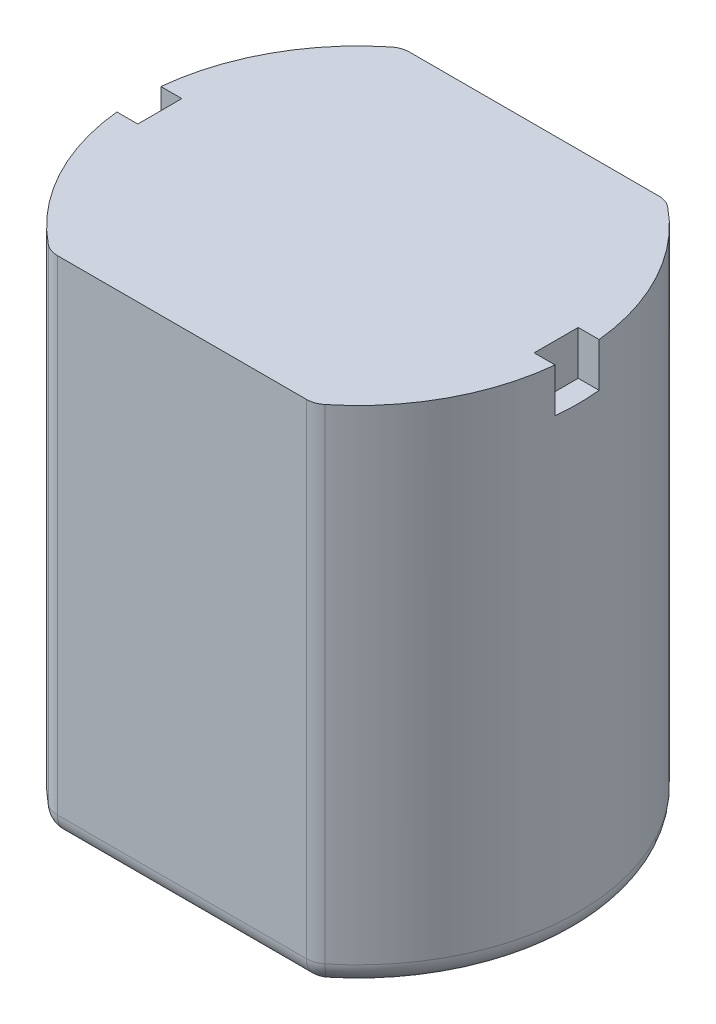
from build123d import *

# Parameters (mm, degrees)
BOSS_EXTRUDE1_DEPTH = 11.5
SKETCH3_W           = 1
SKETCH3_H           = 1
CUT_EXTRUDE1_DEPTH  = 0.5
FILLET1_R           = 0.5
FILLET2_R           = 0.5
SKETCH4_R           = 2
BOSS_EXTRUDE3_DEPTH = 0.25
SKETCH5_R           = 0.25
BOSS_EXTRUDE4_DEPTH = 2.5
SKETCH6_R           = 0.376312749
SKETCH6_R_2         = 0.431953985
CUT_EXTRUDE2_DEPTH  = 0.5


with BuildPart() as part:
    # Sketch1 → Boss-Extrude1 (new body)
    with BuildSketch(Plane(origin=(0, 0, 0), x_dir=(1, 0, 0), z_dir=(0, 1, 0))):
        with BuildLine():
            Line((-3, 4), (3, 4))
            ThreePointArc((3, 4), (5, 0), (3, -4))
            Line((3, -4), (-3, -4))
            ThreePointArc((-3, -4), (-5, 0), (-3, 4))
        make_face()
    extrude(amount=BOSS_EXTRUDE1_DEPTH)

    # Sketch3 → Cut-Extrude1 (cut)
    with BuildSketch(Plane(origin=(5, 0, 0), x_dir=(0, 0, -1), z_dir=(1, 0, 0))):
        with Locations((0, 11)):
            Rectangle(SKETCH3_W, SKETCH3_H)
    cut_extrude1 = extrude(amount=-CUT_EXTRUDE1_DEPTH, mode=Mode.SUBTRACT)

    # Mirror1: Cut-Extrude1 across plane
    add(cut_extrude1.mirror(Plane(origin=(0, 0, 0), x_dir=(0, 0, 1), z_dir=(1, 0, 0))), mode=Mode.SUBTRACT)

    # Fillet1
    fillet1_edges = [part.edges().sort_by_distance(p)[0] for p in [
        (-3, 5.75, -4),
        (-3, 5.75, 4),
        (3, 5.75, 4),
        (3, 5.75, -4),
    ]]
    fillet(fillet1_edges, radius=FILLET1_R)

    # Fillet2
    fillet2_edges = [part.edges().sort_by_distance(p)[0] for p in [
        (-5, 0, 0),
        (0, 0, -4),
        (5, 0, 0),
        (0, 0, 4),
        (2.995093791, 0, 3.971404521),
        (-2.995093791, 0, 3.971404521),
        (2.995093791, 0, -3.971404521),
        (-2.995093791, 0, -3.971404521),
    ]]
    fillet(fillet2_edges, radius=FILLET2_R)

    # Sketch4 → Boss-Extrude3 (add)
    with BuildSketch(Plane.XZ):
        Circle(SKETCH4_R)
    extrude(amount=BOSS_EXTRUDE3_DEPTH)

    # Sketch5 → Boss-Extrude4 (add)
    with BuildSketch(Plane.XZ.offset(0.25)):
        Circle(SKETCH5_R)
    extrude(amount=BOSS_EXTRUDE4_DEPTH)

    # Sketch6 → Cut-Extrude2 (cut)
    with BuildSketch(Plane.XZ):
        with Locations((-3, 0)):
            Circle(SKETCH6_R)
        with Locations((3, 0)):
            Circle(SKETCH6_R_2)
    extrude(amount=-CUT_EXTRUDE2_DEPTH, mode=Mode.SUBTRACT)


solid = part.part
